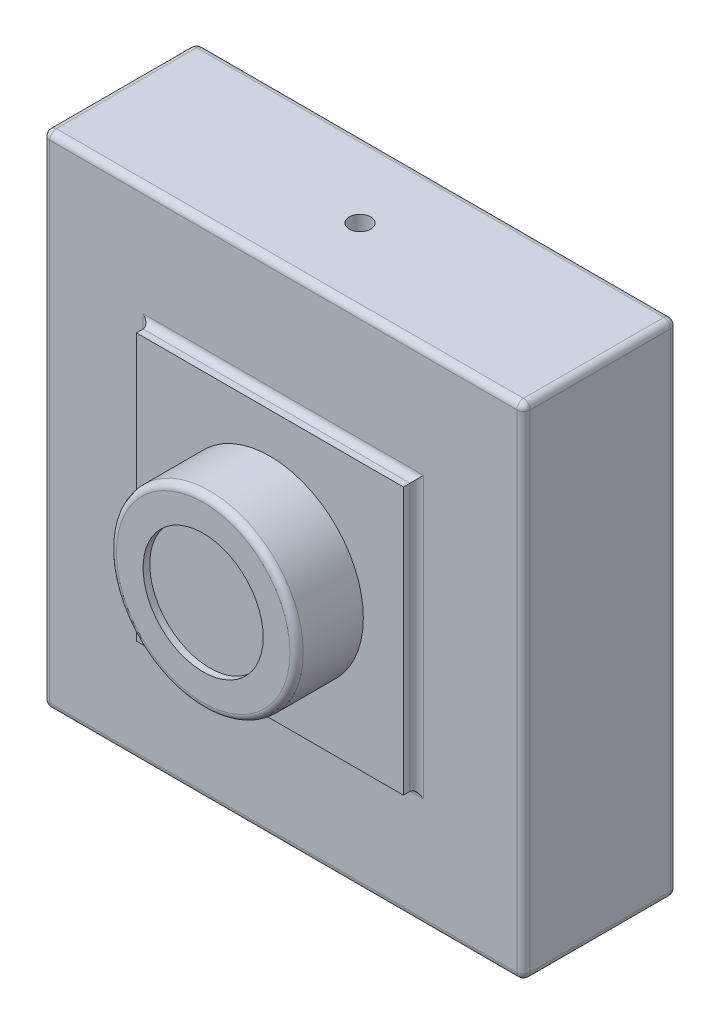
from build123d import *

# Parameters (mm, degrees)
SKETCH_1_W          = 36
SKETCH_1_H          = 37.5
EXTRUDE_1_DEPTH     = 11.5
SKETCH_2_W          = 20
SKETCH_2_H          = 20
EXTRUDE_2_DEPTH     = 1
SKETCH_3_R          = 7
EXTRUDE_3_DEPTH     = 5
FILLET_1_R          = 0.5
SKETCH_4_R          = 4.5
CUT_EXTRUDE_1_DEPTH = 0.5


with BuildPart() as part:
    # 草图1 → 凸台-拉伸1 (new body)
    with BuildSketch(Plane.XY):
        Rectangle(SKETCH_1_W, SKETCH_1_H)
    extrude(amount=EXTRUDE_1_DEPTH)

    # 草图2 → 凸台-拉伸2 (add)
    with BuildSketch(Plane.XY.offset(11.5)):
        Rectangle(SKETCH_2_W, SKETCH_2_H)
    extrude(amount=EXTRUDE_2_DEPTH)

    # 草图3 → 凸台-拉伸3 (add)
    with BuildSketch(Plane.XY.offset(12.5)):
        Circle(SKETCH_3_R)
    extrude(amount=EXTRUDE_3_DEPTH)

    # 圆角1
    fillet_1_edges = [part.edges().sort_by_distance(p)[0] for p in [
        (18, 0, 11.5),
        (0, 18.75, 11.5),
        (-10, 0, 11.5),
        (0, -10, 11.5),
        (10, 0, 11.5),
        (0, 10, 11.5),
        (-7, 0, 17.5),
        (-18, 0, 11.5),
        (0, 18.75, 0),
        (18, 0, 0),
        (0, -18.75, 0),
        (-18, 0, 0),
        (0, -18.75, 11.5),
        (-18, 18.75, 5.75),
        (18, 18.75, 5.75),
        (18, -18.75, 5.75),
        (-18, -18.75, 5.75),
    ]]
    fillet(fillet_1_edges, radius=FILLET_1_R)

    # 草图4 → 切除-拉伸1 (cut)
    with BuildSketch(Plane.XY.offset(17.5)):
        Circle(SKETCH_4_R)
    extrude(amount=-CUT_EXTRUDE_1_DEPTH, mode=Mode.SUBTRACT)

    # 草图6 → M2 螺纹孔1 (revolve, cut)
    with BuildSketch(Plane(origin=(0, -18.75, 5.75), x_dir=(0, 0, -1), z_dir=(1, 0, 0))):
        Polygon((0, 0), (0, 20.480688495), (0.8, 20), (0.8, 0), align=None)
    hole_wizard_m2_1 = revolve(axis=Axis((0, -25.1, 5.75), (0, 1, 0)), mode=Mode.SUBTRACT)

    # 镜向1: M2 螺纹孔1 across plane
    add(hole_wizard_m2_1.mirror(Plane.ZX), mode=Mode.SUBTRACT)


solid = part.part
